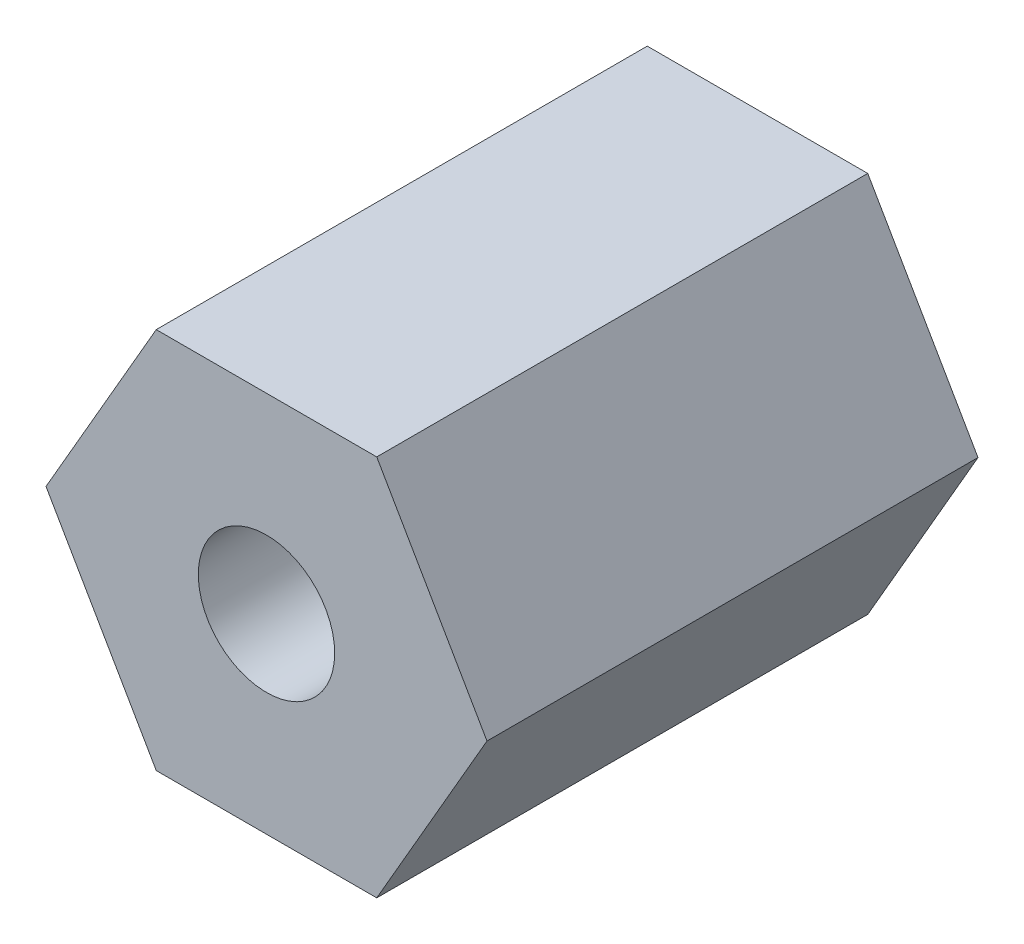
from build123d import *

# Parameters (mm, degrees)
EXTRUDE_1_DEPTH = 9
M3X0_5_1_D      = 2.5


with BuildPart() as part:
    # 草圖1 → 填料-伸長1 (new body)
    with BuildSketch(Plane.XY):
        Polygon((-2.020725942, 3.5), (-4.041451884, 0), (-2.020725942, -3.5), (2.020725942, -3.5), (4.041451884, 0), (2.020725942, 3.5), align=None)
    extrude(amount=EXTRUDE_1_DEPTH)

    # M3x0.5 螺紋孔1 (through all)
    with Locations(Plane.XY.offset(9)):
        with Locations((0, 0)):
            Hole(M3X0_5_1_D / 2)


solid = part.part
